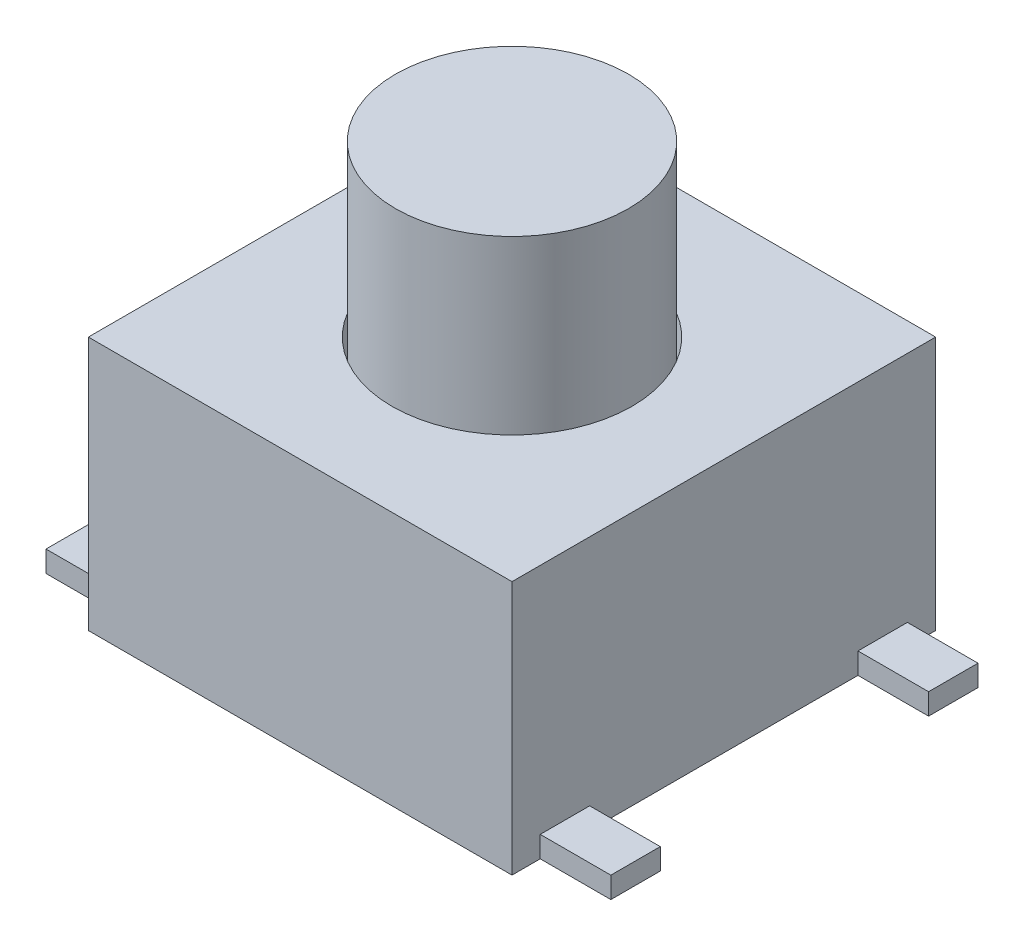
from build123d import *

# Parameters (mm, degrees)
SKETCH_1_W          = 6
SKETCH_1_H          = 6
EXTRUDE_1_DEPTH     = 3.6
SKETCH_2_W          = 0.7
SKETCH_2_H          = 0.3
EXTRUDE_2_DEPTH     = 1
SKETCH_3_R          = 1.7
CUT_EXTRUDE_1_DEPTH = 2.6
SKETCH_4_R          = 1.65
EXTRUDE_3_DEPTH     = 5


with BuildPart() as part:
    # 草图1 → 凸台-拉伸1 (new body)
    with BuildSketch(Plane(origin=(0, 0, 0), x_dir=(1, 0, 0), z_dir=(0, 1, 0))):
        Rectangle(SKETCH_1_W, SKETCH_1_H)
    extrude(amount=EXTRUDE_1_DEPTH)

    # 草图2 → 凸台-拉伸2 (add)
    with BuildSketch(Plane.ZY.offset(3)):
        with Locations((-2.25, 0.15)):
            Rectangle(SKETCH_2_W, SKETCH_2_H)
        with Locations((2.25, 0.15)):
            Rectangle(SKETCH_2_W, SKETCH_2_H)
    extrude_2 = extrude(amount=EXTRUDE_2_DEPTH)

    # 镜向1: 凸台-拉伸2 across plane
    add(extrude_2.mirror(Plane(origin=(0, 0, 0), x_dir=(0, 0, 1), z_dir=(1, 0, 0))))

    # 草图3 → 切除-拉伸1 (cut)
    with BuildSketch(Plane(origin=(0, 3.6, 0), x_dir=(1, 0, 0), z_dir=(0, 1, 0))):
        Circle(SKETCH_3_R)
    extrude(amount=-CUT_EXTRUDE_1_DEPTH, mode=Mode.SUBTRACT)


with BuildPart() as body_2:
    # 草图4 → 凸台-拉伸3 (new body)
    with BuildSketch(Plane(origin=(0, 1, 0), x_dir=(1, 0, 0), z_dir=(0, 1, 0))):
        Circle(SKETCH_4_R)
    extrude(amount=EXTRUDE_3_DEPTH)


solid = Compound([part.part, body_2.part])
